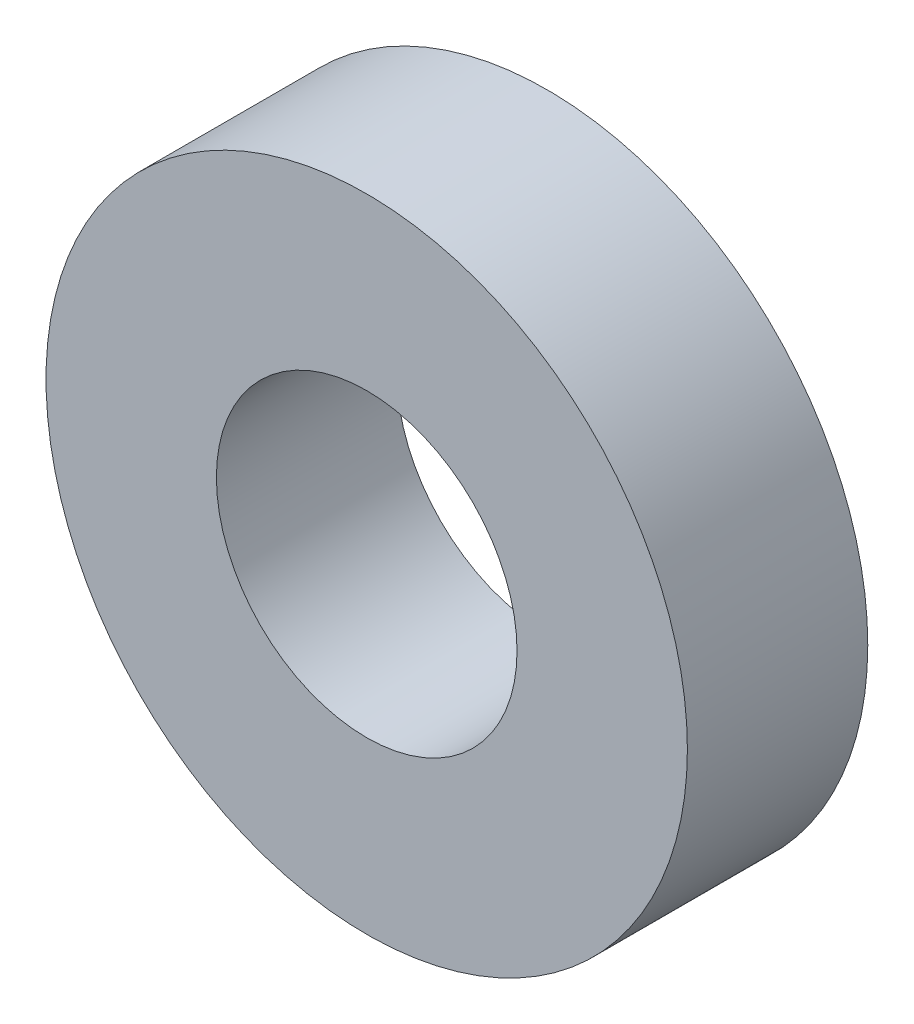
from build123d import *

# Parameters (mm, degrees)
SKETCH1_R           = 16
BOSS_EXTRUDE1_DEPTH = 9
SKETCH2_R           = 7.5
CUT_EXTRUDE1_DEPTH  = 10


with BuildPart() as part:
    # Sketch1 → Boss-Extrude1 (new body)
    with BuildSketch(Plane.XY):
        Circle(SKETCH1_R)
    extrude(amount=BOSS_EXTRUDE1_DEPTH)

    # Sketch2 → Cut-Extrude1 (cut, through all)
    with BuildSketch(Plane.XY.offset(9)):
        Circle(SKETCH2_R)
    extrude(amount=-CUT_EXTRUDE1_DEPTH, mode=Mode.SUBTRACT)


solid = part.part
